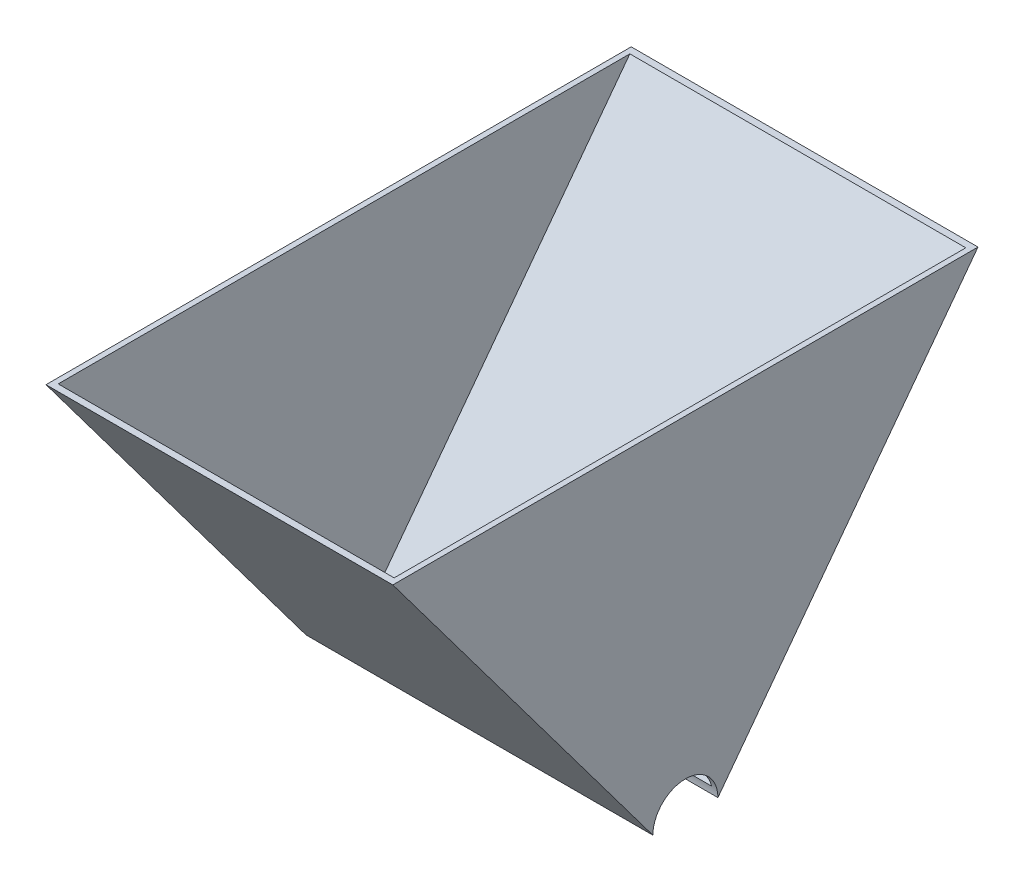
from build123d import *

# Parameters (mm, degrees)
BOSS_EXTRUDE1_DEPTH = 101.6
SHELL3_T            = -1.5875


with BuildPart() as part:
    # Sketch1 → Boss-Extrude1 (new body)
    with BuildSketch(Plane(origin=(0, 0, 0), x_dir=(0, 0, -1), z_dir=(1, 0, 0))):
        with BuildLine():
            Line((-9.525, 0), (-85.725, 101.6))
            Line((-85.725, 101.6), (85.725, 101.6))
            Line((85.725, 101.6), (9.525, 0))
            ThreePointArc((9.525, 0), (0, 9.525), (-9.525, 0))
        make_face()
    extrude(amount=BOSS_EXTRUDE1_DEPTH)

    # Shell3
    shell3_openings = [part.faces().sort_by_distance(p)[0] for p in [
        (50.8, 101.6, 0),
        (50.8, 4.7625, 0),
    ]]
    offset(amount=SHELL3_T, openings=shell3_openings, kind=Kind.INTERSECTION)


solid = part.part
